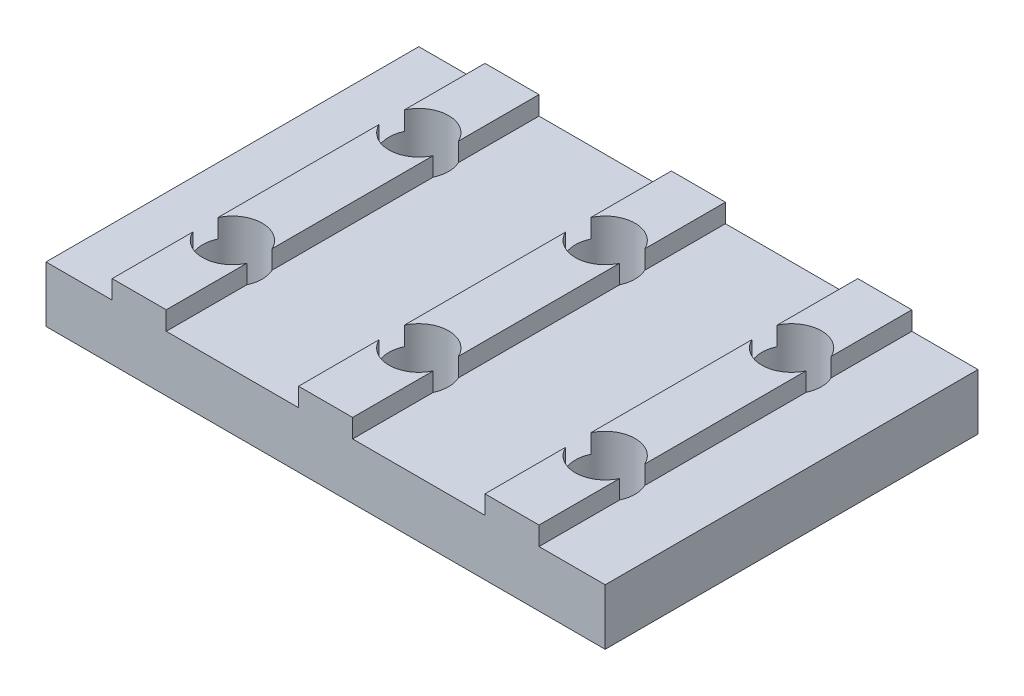
from build123d import *

# Parameters (mm, degrees)
MAIN_DEPTH                 = 20
ESQUISSE2_R                = 1.6
TOPHOLE_DEPTH              = 22
R_P_TITION_LIN_AIRE1_COUNT = 3
R_P_TITION_LIN_AIRE1_PITCH = 10


with BuildPart() as part:
    # Esquisse1 → Main (new body)
    with BuildSketch(Plane.XY):
        Polygon((-5, 0), (-5, 3), (-1.45, 3), (-1.45, 4), (1.45, 4), (1.45, 3), (5, 3), (5, 0), align=None)
    main = extrude(amount=MAIN_DEPTH)

    # Esquisse2 → TopHole (cut, through all)
    with BuildSketch(Plane(origin=(0, 4, 0), x_dir=(1, 0, 0), z_dir=(0, 1, 0))):
        with Locations((0, -5)):
            Circle(ESQUISSE2_R)
        with Locations((0, -15)):
            Circle(ESQUISSE2_R)
    tophole = extrude(amount=-TOPHOLE_DEPTH, mode=Mode.SUBTRACT)

    # Répétition linéaire1: Main, TopHole ×3
    with Locations(*[(-i * R_P_TITION_LIN_AIRE1_PITCH, 0, 0) for i in range(1, R_P_TITION_LIN_AIRE1_COUNT)]):
        add(main)
        add(tophole, mode=Mode.SUBTRACT)


solid = part.part
